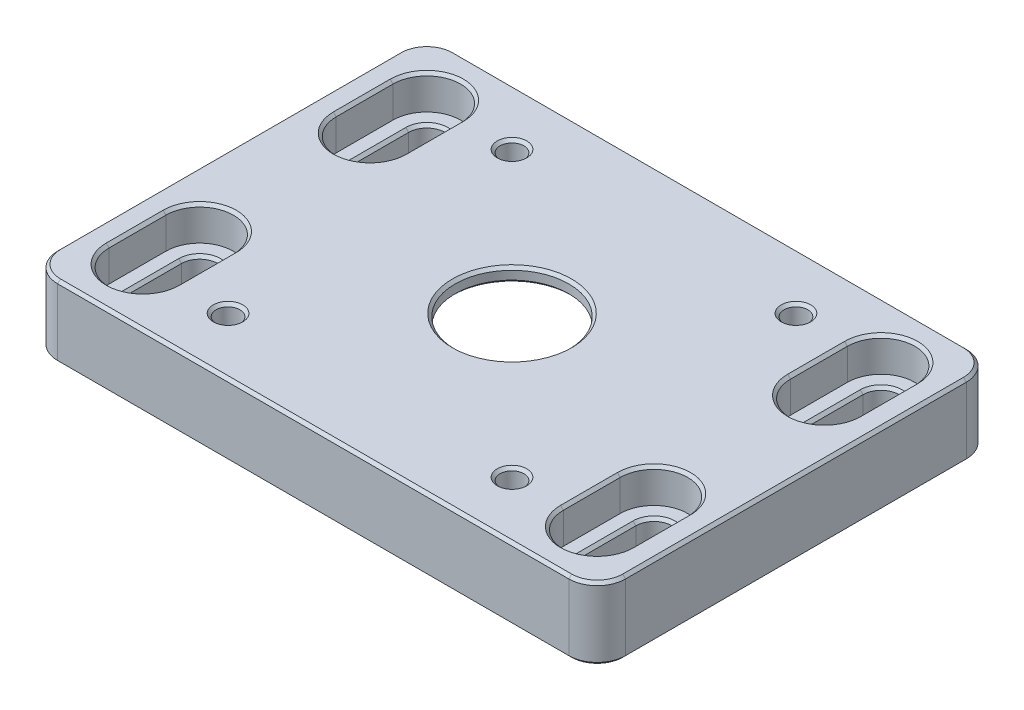
from build123d import *

# Parameters (mm, degrees)
SKETCH1_W           = 100
SKETCH1_H           = 70
BOSS_EXTRUDE1_DEPTH = 12.7
SKETCH2_R           = 25
CUT_EXTRUDE1_DEPTH  = 3
SKETCH3_R           = 10
CUT_EXTRUDE2_DEPTH  = 10.7
SKETCH4_R           = 2.1
CUT_EXTRUDE3_DEPTH  = 13.7
SKETCH5_W           = 60.5
SKETCH5_H           = 60.5
CUT_EXTRUDE4_DEPTH  = 7
FILLET1_R           = 3
FILLET2_R           = 5
CUT_EXTRUDE5_DEPTH  = 13.7
SKETCH7_R           = 25.25
CUT_EXTRUDE6_DEPTH  = 3.2
CUT_EXTRUDE7_DEPTH  = 6
CHAMFER1_SIZE       = 0.5


with BuildPart() as part:
    # Sketch1 → Boss-Extrude1 (new body)
    with BuildSketch(Plane(origin=(0, 0, 0), x_dir=(1, 0, 0), z_dir=(0, 1, 0))):
        Rectangle(SKETCH1_W, SKETCH1_H)
    extrude(amount=BOSS_EXTRUDE1_DEPTH)

    # Sketch2 → Cut-Extrude1 (cut)
    with BuildSketch(Plane.XZ):
        Circle(SKETCH2_R)
    extrude(amount=-CUT_EXTRUDE1_DEPTH, mode=Mode.SUBTRACT)

    # Sketch3 → Cut-Extrude2 (cut, through all)
    with BuildSketch(Plane.XZ.offset(-3)):
        Circle(SKETCH3_R)
    extrude(amount=-CUT_EXTRUDE2_DEPTH, mode=Mode.SUBTRACT)

    # Sketch4 → Cut-Extrude3 (cut, through all)
    with BuildSketch(Plane.XZ):
        with Locations((-25, 25)):
            Circle(SKETCH4_R)
        with Locations((25, 25)):
            Circle(SKETCH4_R)
        with Locations((25, -25)):
            Circle(SKETCH4_R)
        with Locations((-25, -25)):
            Circle(SKETCH4_R)
    extrude(amount=-CUT_EXTRUDE3_DEPTH, mode=Mode.SUBTRACT)

    # Sketch5 → Cut-Extrude4 (cut)
    with BuildSketch(Plane.XZ):
        Rectangle(SKETCH5_W, SKETCH5_H)
    extrude(amount=-CUT_EXTRUDE4_DEPTH, mode=Mode.SUBTRACT)

    # Fillet1
    fillet1_edges = [part.edges().sort_by_distance(p)[0] for p in [
        (-30.25, 3.5, -30.25),
        (-30.25, 3.5, 30.25),
        (30.25, 3.5, 30.25),
        (30.25, 3.5, -30.25),
    ]]
    fillet(fillet1_edges, radius=FILLET1_R)

    # Fillet2
    fillet2_edges = [part.edges().sort_by_distance(p)[0] for p in [
        (-50, 6.35, -35),
        (50, 6.35, -35),
        (50, 6.35, 35),
        (-50, 6.35, 35),
    ]]
    fillet(fillet2_edges, radius=FILLET2_R)

    # Sketch6 → Cut-Extrude5 (cut, through all)
    with BuildSketch(Plane(origin=(0, 12.7, 0), x_dir=(1, 0, 0), z_dir=(0, 1, 0))):
        with BuildLine():
            Line((-36.8, 25), (-36.8, 15))
            ThreePointArc((-36.8, 15), (-40, 11.8), (-43.2, 15))
            Line((-43.2, 15), (-43.2, 25))
            ThreePointArc((-43.2, 25), (-40, 28.2), (-36.8, 25))
        make_face()
        with BuildLine():
            Line((-36.8, -25), (-36.8, -15))
            ThreePointArc((-36.8, -15), (-40, -11.8), (-43.2, -15))
            Line((-43.2, -15), (-43.2, -25))
            ThreePointArc((-43.2, -25), (-40, -28.2), (-36.8, -25))
        make_face()
        with BuildLine():
            Line((36.8, -25), (36.8, -15))
            ThreePointArc((36.8, -15), (40, -11.8), (43.2, -15))
            Line((43.2, -15), (43.2, -25))
            ThreePointArc((43.2, -25), (40, -28.2), (36.8, -25))
        make_face()
        with BuildLine():
            Line((36.8, 25), (36.8, 15))
            ThreePointArc((36.8, 15), (40, 11.8), (43.2, 15))
            Line((43.2, 15), (43.2, 25))
            ThreePointArc((43.2, 25), (40, 28.2), (36.8, 25))
        make_face()
    extrude(amount=-CUT_EXTRUDE5_DEPTH, mode=Mode.SUBTRACT)

    # Sketch7 → Cut-Extrude6 (cut)
    with BuildSketch(Plane.XZ.offset(-7)):
        Circle(SKETCH7_R)
    extrude(amount=-CUT_EXTRUDE6_DEPTH, mode=Mode.SUBTRACT)

    # Sketch9 → Cut-Extrude7 (cut)
    with BuildSketch(Plane(origin=(0, 12.7, 0), x_dir=(1, 0, 0), z_dir=(0, 1, 0))):
        with BuildLine():
            Line((45.95, 15), (45.95, 25))
            ThreePointArc((45.95, 25), (40, 30.95), (34.05, 25))
            Line((34.05, 25), (34.05, 15))
            ThreePointArc((34.05, 15), (40, 9.05), (45.95, 15))
        make_face()
        with BuildLine():
            Line((34.05, -25), (34.05, -15))
            ThreePointArc((34.05, -15), (40, -9.05), (45.95, -15))
            Line((45.95, -15), (45.95, -25))
            ThreePointArc((45.95, -25), (40, -30.95), (34.05, -25))
        make_face()
        with BuildLine():
            Line((-45.95, -15), (-45.95, -25))
            ThreePointArc((-45.95, -25), (-40, -30.95), (-34.05, -25))
            Line((-34.05, -25), (-34.05, -15))
            ThreePointArc((-34.05, -15), (-40, -9.05), (-45.95, -15))
        make_face()
        with BuildLine():
            Line((-34.05, 25), (-34.05, 15))
            ThreePointArc((-34.05, 15), (-40, 9.05), (-45.95, 15))
            Line((-45.95, 15), (-45.95, 25))
            ThreePointArc((-45.95, 25), (-40, 30.95), (-34.05, 25))
        make_face()
    extrude(amount=-CUT_EXTRUDE7_DEPTH, mode=Mode.SUBTRACT)

    # Chamfer1
    chamfer1_edges = [part.edges().sort_by_distance(p)[0] for p in [
        (40, 0, -28.2),
        (43.2, 0, -20),
        (40, 0, -11.8),
        (36.8, 0, -20),
        (40, 0, 28.2),
        (36.8, 0, 20),
        (40, 0, 11.8),
        (43.2, 0, 20),
        (-40, 0, 28.2),
        (-43.2, 0, 20),
        (-40, 0, 11.8),
        (-36.8, 0, 20),
        (-40, 0, -28.2),
        (-36.8, 0, -20),
        (-40, 0, -11.8),
        (-43.2, 0, -20),
        (-25.25, 7, 0),
        (-10, 10.2, 0),
        (36.8, 6.7, -20),
        (43.2, 6.7, 20),
        (-36.8, 6.7, 20),
        (-43.2, 6.7, -20),
        (-10, 12.7, 0),
        (40, 12.7, -9.05),
        (45.95, 12.7, -20),
        (40, 12.7, -30.95),
        (34.05, 12.7, -20),
        (40, 6.7, -28.2),
        (43.2, 6.7, -20),
        (40, 6.7, -11.8),
        (-36.8, 6.7, -20),
        (-40, 6.7, -28.2),
        (-40, 6.7, -11.8),
        (-40, 12.7, -30.95),
        (-45.95, 12.7, -20),
        (-40, 12.7, -9.05),
        (-34.05, 12.7, -20),
        (-40, 12.7, 9.05),
        (-45.95, 12.7, 20),
        (-40, 12.7, 30.95),
        (-34.05, 12.7, 20),
        (-40, 6.7, 28.2),
        (-43.2, 6.7, 20),
        (-40, 6.7, 11.8),
        (36.8, 6.7, 20),
        (40, 6.7, 28.2),
        (40, 6.7, 11.8),
        (40, 12.7, 30.95),
        (45.95, 12.7, 20),
        (40, 12.7, 9.05),
        (34.05, 12.7, 20),
        (-27.1, 12.7, -25),
        (22.9, 12.7, -25),
        (22.9, 12.7, 25),
        (-27.1, 12.7, 25),
        (-27.1, 7, 25),
        (22.9, 7, 25),
        (22.9, 7, -25),
        (-27.1, 7, -25),
        (-50, 0, 0),
        (-50, 12.7, 0),
        (0, 0, -35),
        (50, 0, 0),
        (0, 0, 35),
        (48.535533906, 0, 33.535533906),
        (-48.535533906, 0, 33.535533906),
        (48.535533906, 0, -33.535533906),
        (-48.535533906, 0, -33.535533906),
        (0, 12.7, -35),
        (0, 12.7, 35),
        (50, 12.7, 0),
        (48.535533906, 12.7, 33.535533906),
        (-48.535533906, 12.7, 33.535533906),
        (48.535533906, 12.7, -33.535533906),
        (-48.535533906, 12.7, -33.535533906),
    ]]
    chamfer(chamfer1_edges, length=CHAMFER1_SIZE)


solid = part.part
